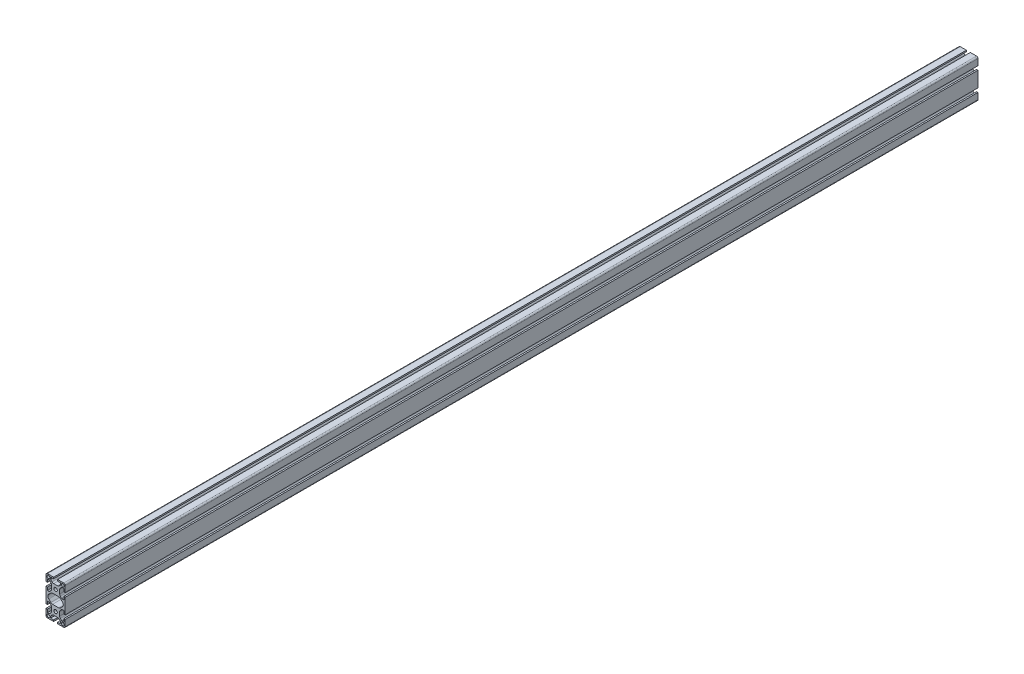
from build123d import *

# Parameters (mm, degrees)
SKETCH1_R           = 3
SKETCH1_R_2         = 3.5
BOSS_EXTRUDE1_DEPTH = 1900


with BuildPart() as part:
    # Sketch1 → Boss-Extrude1 (new body)
    with BuildSketch(Plane.XY):
        with BuildLine():
            Line((-17, -40), (-4.1, -40))
            Line((-4.1, -40), (-4.1, -37))
            Line((-4.1, -37), (-10.5, -37))
            Line((-10.5, -37), (-10.5, -33.6627417))
            ThreePointArc((-10.5, -33.6627417), (-10.378207252, -33.050448208), (-10.03137085, -32.53137085))
            Line((-10.03137085, -32.53137085), (-7.464466094, -29.964466094))
            ThreePointArc((-7.464466094, -29.964466094), (-5.84234935, -28.880602337), (-3.928932188, -28.5))
            Line((-3.928932188, -28.5), (3.928932188, -28.5))
            ThreePointArc((3.928932188, -28.5), (5.84234935, -28.880602337), (7.464466094, -29.964466094))
            Line((7.464466094, -29.964466094), (10.03137085, -32.53137085))
            ThreePointArc((10.03137085, -32.53137085), (10.378207252, -33.050448208), (10.5, -33.6627417))
            Line((10.5, -33.6627417), (10.5, -37))
            Line((10.5, -37), (4.1, -37))
            Line((4.1, -37), (4.1, -40))
            Line((4.1, -40), (17, -40))
            ThreePointArc((17, -40), (19.121320344, -39.121320344), (20, -37))
            Line((20, -37), (20, -24.1))
            Line((20, -24.1), (17, -24.1))
            Line((17, -24.1), (17, -30.5))
            Line((17, -30.5), (13.6627417, -30.5))
            ThreePointArc((13.6627417, -30.5), (13.050448208, -30.378207252), (12.53137085, -30.03137085))
            Line((12.53137085, -30.03137085), (9.964466094, -27.464466094))
            ThreePointArc((9.964466094, -27.464466094), (8.880602337, -25.84234935), (8.5, -23.928932188))
            Line((8.5, -23.928932188), (8.5, -16.071067812))
            ThreePointArc((8.5, -16.071067812), (8.880602337, -14.15765065), (9.964466094, -12.535533906))
            Line((9.964466094, -12.535533906), (12.53137085, -9.96862915))
            ThreePointArc((12.53137085, -9.96862915), (13.050448208, -9.621792748), (13.6627417, -9.5))
            Line((13.6627417, -9.5), (17, -9.5))
            Line((17, -9.5), (17, -15.9))
            Line((17, -15.9), (20, -15.9))
            Line((20, -15.9), (20, 15.9))
            Line((20, 15.9), (17, 15.9))
            Line((17, 15.9), (17, 9.5))
            Line((17, 9.5), (13.6627417, 9.5))
            ThreePointArc((13.6627417, 9.5), (13.050448208, 9.621792748), (12.53137085, 9.96862915))
            Line((12.53137085, 9.96862915), (9.964466094, 12.535533906))
            ThreePointArc((9.964466094, 12.535533906), (8.880602337, 14.15765065), (8.5, 16.071067812))
            Line((8.5, 16.071067812), (8.5, 23.928932188))
            ThreePointArc((8.5, 23.928932188), (8.880602337, 25.84234935), (9.964466094, 27.464466094))
            Line((9.964466094, 27.464466094), (12.53137085, 30.03137085))
            ThreePointArc((12.53137085, 30.03137085), (13.050448208, 30.378207252), (13.6627417, 30.5))
            Line((13.6627417, 30.5), (17, 30.5))
            Line((17, 30.5), (17, 24.1))
            Line((17, 24.1), (20, 24.1))
            Line((20, 24.1), (20, 37))
            ThreePointArc((20, 37), (19.121320344, 39.121320344), (17, 40))
            Line((17, 40), (4.1, 40))
            Line((4.1, 40), (4.1, 37))
            Line((4.1, 37), (10.5, 37))
            Line((10.5, 37), (10.5, 33.6627417))
            ThreePointArc((10.5, 33.6627417), (10.378207252, 33.050448208), (10.03137085, 32.53137085))
            Line((10.03137085, 32.53137085), (7.464466094, 29.964466094))
            ThreePointArc((7.464466094, 29.964466094), (5.84234935, 28.880602337), (3.928932188, 28.5))
            Line((3.928932188, 28.5), (-3.928932188, 28.5))
            ThreePointArc((-3.928932188, 28.5), (-5.84234935, 28.880602337), (-7.464466094, 29.964466094))
            Line((-7.464466094, 29.964466094), (-10.03137085, 32.53137085))
            ThreePointArc((-10.03137085, 32.53137085), (-10.378207252, 33.050448208), (-10.5, 33.6627417))
            Line((-10.5, 33.6627417), (-10.5, 37))
            Line((-10.5, 37), (-4.1, 37))
            Line((-4.1, 37), (-4.1, 40))
            Line((-4.1, 40), (-17, 40))
            ThreePointArc((-17, 40), (-19.121320344, 39.121320344), (-20, 37))
            Line((-20, 37), (-20, 24.1))
            Line((-20, 24.1), (-17, 24.1))
            Line((-17, 24.1), (-17, 30.5))
            Line((-17, 30.5), (-13.6627417, 30.5))
            ThreePointArc((-13.6627417, 30.5), (-13.050448208, 30.378207252), (-12.53137085, 30.03137085))
            Line((-12.53137085, 30.03137085), (-9.964466094, 27.464466094))
            ThreePointArc((-9.964466094, 27.464466094), (-8.880602337, 25.84234935), (-8.5, 23.928932188))
            Line((-8.5, 23.928932188), (-8.5, 16.071067812))
            ThreePointArc((-8.5, 16.071067812), (-8.880602337, 14.15765065), (-9.964466094, 12.535533906))
            Line((-9.964466094, 12.535533906), (-12.53137085, 9.96862915))
            ThreePointArc((-12.53137085, 9.96862915), (-13.050448208, 9.621792748), (-13.6627417, 9.5))
            Line((-13.6627417, 9.5), (-17, 9.5))
            Line((-17, 9.5), (-17, 15.9))
            Line((-17, 15.9), (-20, 15.9))
            Line((-20, 15.9), (-20, -15.9))
            Line((-20, -15.9), (-17, -15.9))
            Line((-17, -15.9), (-17, -9.5))
            Line((-17, -9.5), (-13.6627417, -9.5))
            ThreePointArc((-13.6627417, -9.5), (-13.050448208, -9.621792748), (-12.53137085, -9.96862915))
            Line((-12.53137085, -9.96862915), (-9.964466094, -12.535533906))
            ThreePointArc((-9.964466094, -12.535533906), (-8.880602337, -14.15765065), (-8.5, -16.071067812))
            Line((-8.5, -16.071067812), (-8.5, -23.928932188))
            ThreePointArc((-8.5, -23.928932188), (-8.880602337, -25.84234935), (-9.964466094, -27.464466094))
            Line((-9.964466094, -27.464466094), (-12.53137085, -30.03137085))
            ThreePointArc((-12.53137085, -30.03137085), (-13.050448208, -30.378207252), (-13.6627417, -30.5))
            Line((-13.6627417, -30.5), (-17, -30.5))
            Line((-17, -30.5), (-17, -24.1))
            Line((-17, -24.1), (-20, -24.1))
            Line((-20, -24.1), (-20, -37))
            ThreePointArc((-20, -37), (-19.121320344, -39.121320344), (-17, -40))
        make_face()
        with Locations((15, 35)):
            Circle(SKETCH1_R, mode=Mode.SUBTRACT)
        with Locations((15, -35)):
            Circle(SKETCH1_R, mode=Mode.SUBTRACT)
        with Locations((0, 20)):
            Circle(SKETCH1_R_2, mode=Mode.SUBTRACT)
        with Locations((0, -20)):
            Circle(SKETCH1_R_2, mode=Mode.SUBTRACT)
        with Locations((-15, 35)):
            Circle(SKETCH1_R, mode=Mode.SUBTRACT)
        with Locations((-15, -35)):
            Circle(SKETCH1_R, mode=Mode.SUBTRACT)
        with BuildLine():
            Line((-14.242640687, -4.242640687), (-9.949747468, -8.535533906))
            ThreePointArc((-9.949747468, -8.535533906), (-8.327630724, -9.619397663), (-6.414213562, -10))
            Line((-6.414213562, -10), (6.414213562, -10))
            ThreePointArc((6.414213562, -10), (8.327630724, -9.619397663), (9.949747468, -8.535533906))
            Line((9.949747468, -8.535533906), (14.242640687, -4.242640687))
            ThreePointArc((14.242640687, -4.242640687), (16, 0), (14.242640687, 4.242640687))
            Line((14.242640687, 4.242640687), (9.949747468, 8.535533906))
            ThreePointArc((9.949747468, 8.535533906), (8.327630724, 9.619397663), (6.414213562, 10))
            Line((6.414213562, 10), (-6.414213562, 10))
            ThreePointArc((-6.414213562, 10), (-8.327630724, 9.619397663), (-9.949747468, 8.535533906))
            Line((-9.949747468, 8.535533906), (-14.242640687, 4.242640687))
            ThreePointArc((-14.242640687, 4.242640687), (-16, 0), (-14.242640687, -4.242640687))
        make_face(mode=Mode.SUBTRACT)
    extrude(amount=-BOSS_EXTRUDE1_DEPTH)


solid = part.part
